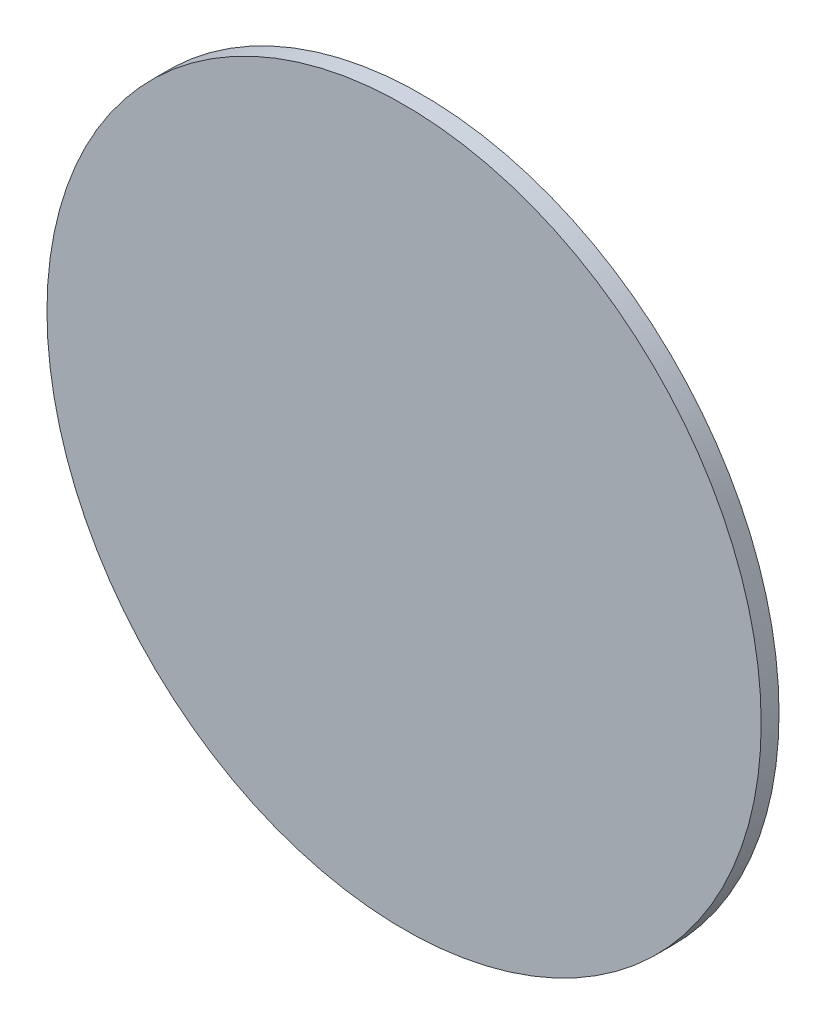
from build123d import *

# Parameters (mm, degrees)
SKETCH1_R           = 63.5
BOSS_EXTRUDE1_DEPTH = 3.175


with BuildPart() as part:
    # Sketch1 → Boss-Extrude1 (new body)
    with BuildSketch(Plane.XY):
        Circle(SKETCH1_R)
    extrude(amount=BOSS_EXTRUDE1_DEPTH)


solid = part.part
